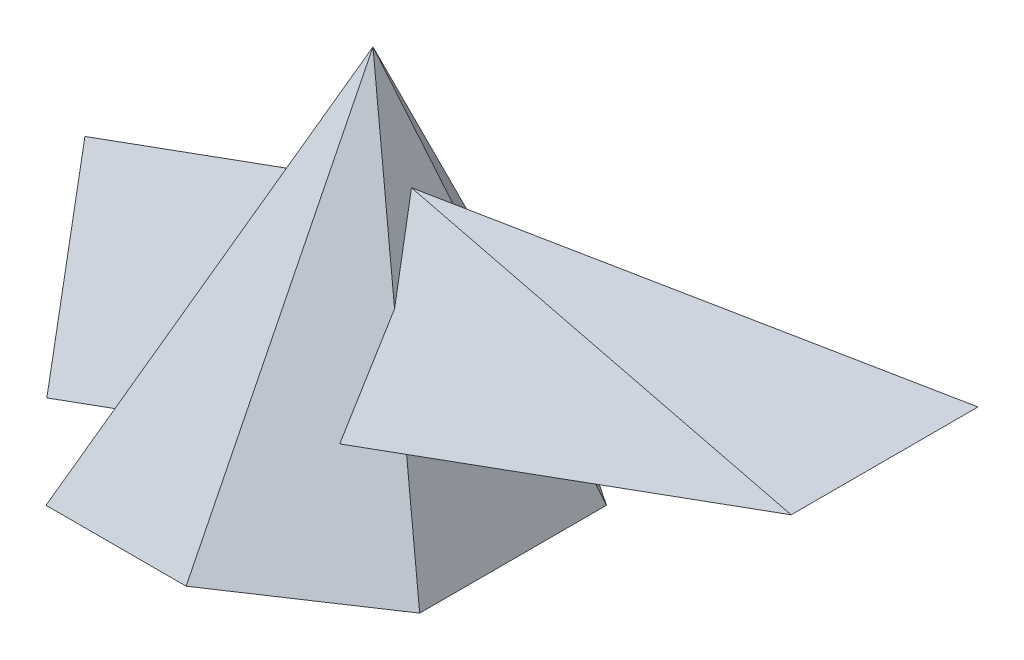
from build123d import *

# Parameters (mm, degrees)
TRIANGULAR_PRISM_DEPTH      = 100
TRIANGULAR_PRISM_DEPTH_BACK = 100
LHS_CUT_DEPTH               = 41.0000001
LHS_CUT_DEPTH_BACK          = 41.0000001
RHS_CUT_DEPTH               = 41.0000001
RHS_CUT_DEPTH_BACK          = 41.0000001


with BuildPart() as part:
    # Base → Loft of pyramid section 0
    with BuildSketch(Plane(origin=(0, 0, 0), x_dir=(1, 0, 0), z_dir=(0, 1, 0)), mode=Mode.PRIVATE) as loft_of_pyramid_s0:
        Polygon((0, 40), (0, -40), (30, -40), (60, -20), (60, 20), (30, 40), align=None)
    loft([loft_of_pyramid_s0.sketch, Vertex(30, 80, 0)])

    # 40mm triangle → Triangular Prism (add, two sides)
    with BuildSketch(Plane(origin=(52.416440656, 19.078024185, 0), x_dir=(0, 0, 1), z_dir=(-0.939692621, -0.342020143, 0))) as triangular_prism_sk:
        Polygon((0, 41.419901523), (20, 6.778885372), (-20, 6.778885372), align=None)
    extrude(amount=TRIANGULAR_PRISM_DEPTH)
    extrude(triangular_prism_sk.sketch, amount=-TRIANGULAR_PRISM_DEPTH_BACK)

    # Sketch6 → LHS cut (cut, two sides)
    with BuildSketch(Plane.XY) as lhs_cut_sk:
        Polygon((-19.820134879, 0), (-43.87133677, -8.753921587), (-55.719262079, 23.797985667), (-31.668060188, 32.551907254), align=None)
    extrude(amount=LHS_CUT_DEPTH, mode=Mode.SUBTRACT)
    extrude(lhs_cut_sk.sketch, amount=-LHS_CUT_DEPTH_BACK, mode=Mode.SUBTRACT)

    # Sketch7 → RHS cut (cut, two sides)
    with BuildSketch(Plane.XY) as rhs_cut_sk:
        Polygon((38.25, 58), (139.53355545, 58), (144.067187388, 59.650107079), (132.219262079, 92.202014333), align=None)
    extrude(amount=RHS_CUT_DEPTH, mode=Mode.SUBTRACT)
    extrude(rhs_cut_sk.sketch, amount=-RHS_CUT_DEPTH_BACK, mode=Mode.SUBTRACT)


solid = part.part
